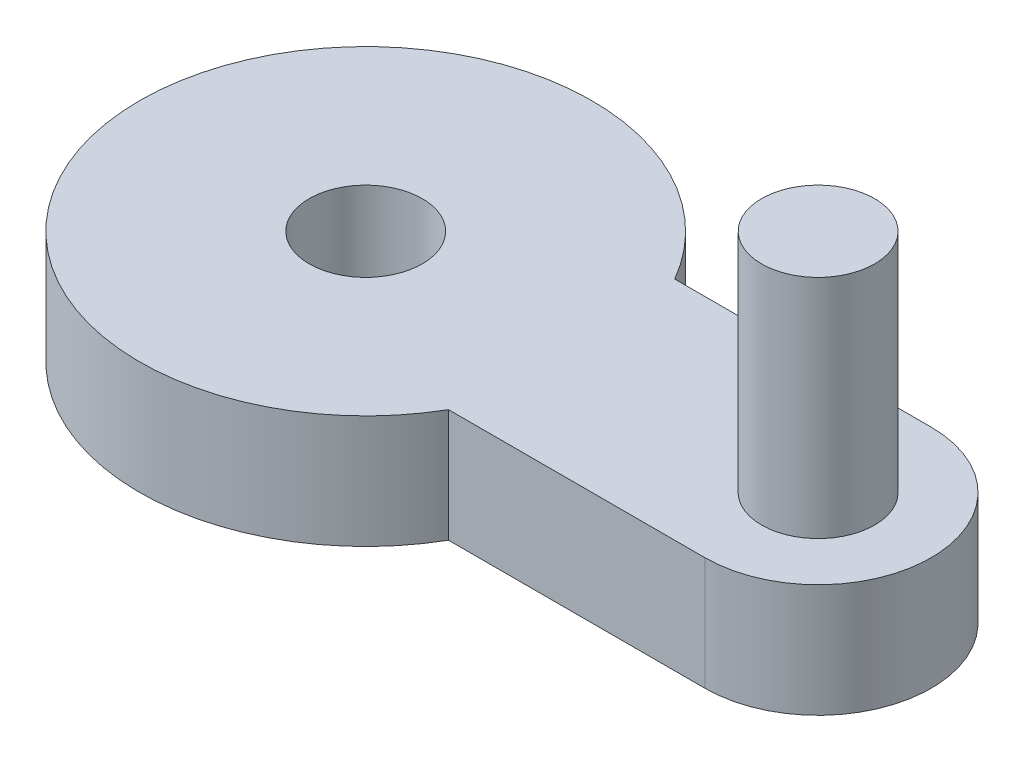
from build123d import *

# Parameters (mm, degrees)
SKETCH1_R           = 2.5
BOSS_EXTRUDE1_DEPTH = 5
SKETCH2_R           = 2.5
BOSS_EXTRUDE2_DEPTH = 10


with BuildPart() as part:
    # Sketch1 → Boss-Extrude1 (new body)
    with BuildSketch(Plane(origin=(0, 0, 0), x_dir=(1, 0, 0), z_dir=(0, 1, 0))):
        with BuildLine():
            Line((8.660254038, 5), (20, 5))
            ThreePointArc((20, 5), (25, 0), (20, -5))
            Line((20, -5), (8.660254038, -5))
            ThreePointArc((8.660254038, -5), (-10, 0), (8.660254038, 5))
        make_face()
        Circle(SKETCH1_R, mode=Mode.SUBTRACT)
    extrude(amount=BOSS_EXTRUDE1_DEPTH)

    # Sketch2 → Boss-Extrude2 (add)
    with BuildSketch(Plane(origin=(0, 5, 0), x_dir=(1, 0, 0), z_dir=(0, 1, 0))):
        with Locations((20, 0)):
            Circle(SKETCH2_R)
    extrude(amount=BOSS_EXTRUDE2_DEPTH)


solid = part.part
